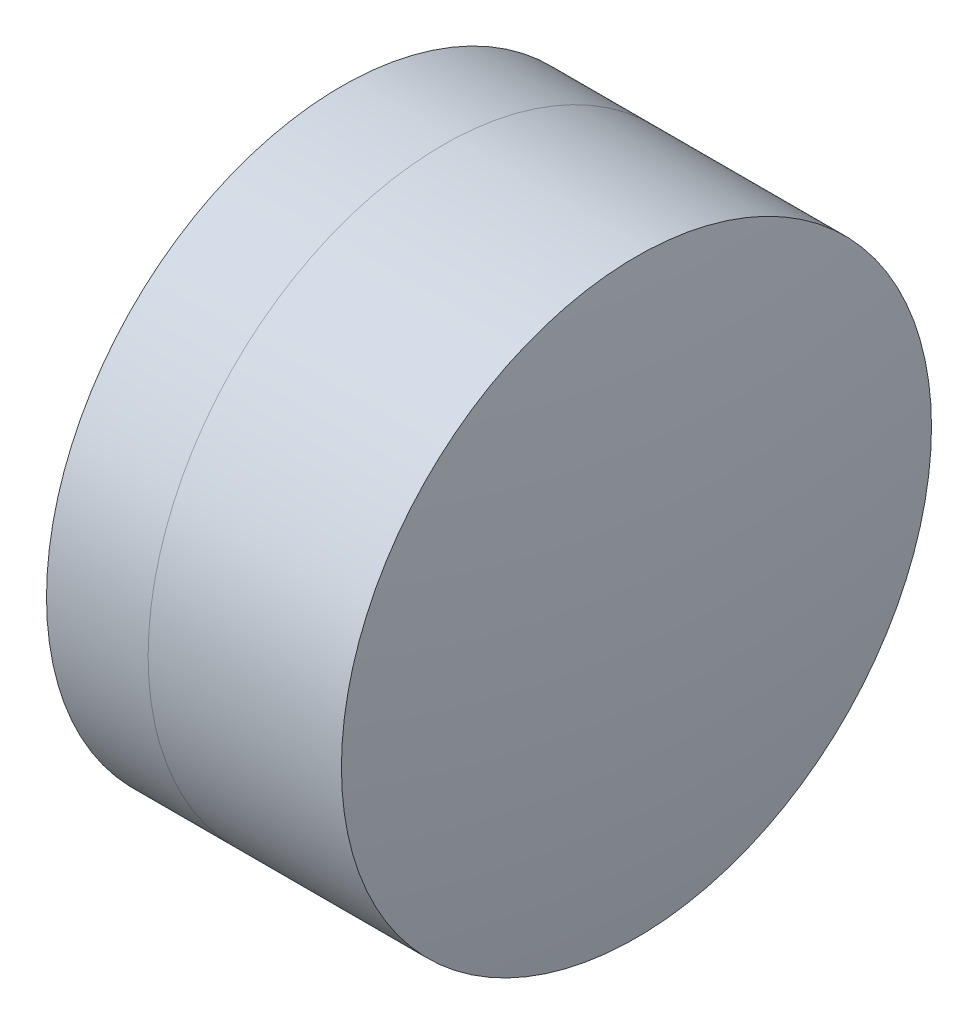
from build123d import *


with BuildPart() as part:
    # 草图1 one side → 旋转1 (revolve)
    with BuildSketch(Plane(origin=(0, 0, 0), x_dir=(1, 0, 0), z_dir=(0, 1, 0)), mode=Mode.PRIVATE) as revolve_1_sk:
        with BuildLine():
            ThreePointArc((-0.359836309, 3.175), (-0.803110454, 1.614926241), (-0.952560574, 0))
            Line((-0.952560574, 0), (1.547439426, 0))
            ThreePointArc((1.547439426, 0), (1.340736719, 1.638825714), (0.733575875, 3.175))
            Line((0.733575875, 3.175), (-0.359836309, 3.175))
        make_face()
    revolve(revolve_1_sk.sketch.rotate(Axis((-9.702612178, 0, 0), (1, 0, 0)), 180), axis=Axis((-9.702612178, 0, 0), (1, 0, 0)))  # turned: the seam where the file's is


with BuildPart() as body_2:
    # 草图2 one side → 旋转3 (revolve)
    with BuildSketch(Plane(origin=(0, 0, 0), x_dir=(1, 0, 0), z_dir=(0, 1, 0)), mode=Mode.PRIVATE) as revolve_3_sk:
        with BuildLine():
            Line((2.813910375, 3.175), (0.733575875, 3.175))
            ThreePointArc((0.733575875, 3.175), (1.340736719, 1.638825714), (1.547439426, 0))
            Line((1.547439426, 0), (3.047439426, 0))
            ThreePointArc((3.047439426, 0), (2.988978415, 1.591788367), (2.813910375, 3.175))
        make_face()
    revolve(revolve_3_sk.sketch.rotate(Axis((-0.551919993, 0, 0), (1, 0, 0)), 180), axis=Axis((-0.551919993, 0, 0), (1, 0, 0)))  # turned: the seam where the file's is


solid = Compound([part.part, body_2.part])
